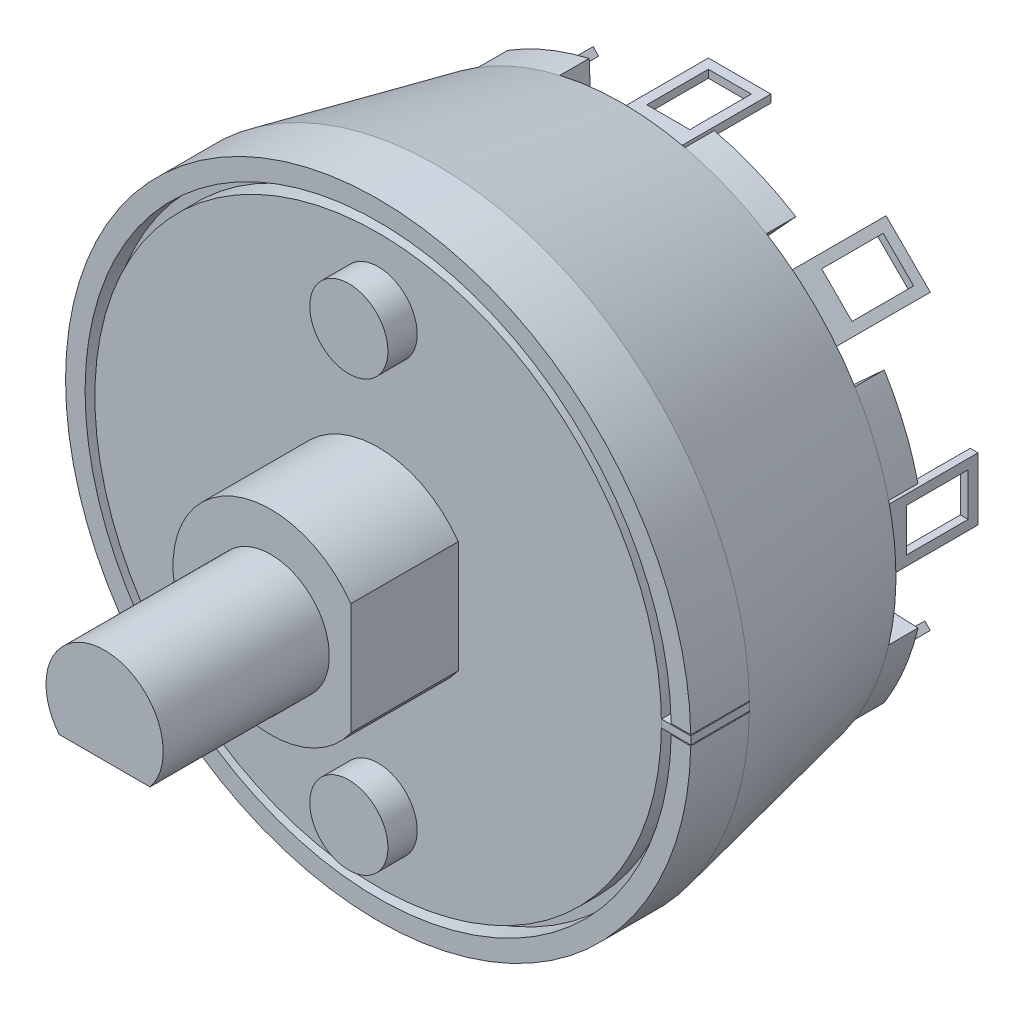
from build123d import *

# Parameters (mm, degrees)
CORTAR_EXTRUIR1_DEPTH   = 6.5
CORTAR_EXTRUIR2_DEPTH   = 5.5
CROQUIS6_R              = 2
SALIENTE_EXTRUIR1_DEPTH = 1.5
CROQUIS10_R             = 15
CROQUIS10_R_2           = 14.5
CORTAR_EXTRUIR5_DEPTH   = 1
CORTAR_EXTRUIR6_DEPTH   = 3
CROQUIS12_W             = 1.498741956
CROQUIS12_H             = 0.4
SALIENTE_EXTRUIR5_DEPTH = 3
SALIENTE_EXTRUIR6_DEPTH = 1.5
CROQUIS13_3_W           = 3.2
CROQUIS13_3_H           = 0.4
CROQUIS13_3_W_2         = 0.4
CROQUIS13_3_H_2         = 1.6
CROQUIS13_3_H_3         = 3.2
SALIENTE_EXTRUIR7_DEPTH = 6
CROQUIS14_W             = 2.2
CROQUIS14_H             = 3.15
CORTAR_EXTRUIR8_DEPTH   = 29.2
CROQUIS16_W             = 3.15
CROQUIS16_H             = 2.2
CORTAR_EXTRUIR10_DEPTH  = 35.827416998
CROQUIS17_W             = 3.15
CROQUIS17_H             = 2.2
CORTAR_EXTRUIR11_DEPTH  = 35.827416998
CROQUIS18_W             = 0.4
CROQUIS18_H             = 3.2
SALIENTE_EXTRUIR8_DEPTH = 6
CROQUIS15_W             = 3.15
CROQUIS15_H             = 2.2
CORTAR_EXTRUIR12_DEPTH  = 29.2


with BuildPart() as part:
    # Croquis3 → Revolución1 (revolve)
    with BuildSketch(Plane(origin=(0, 0, 0), x_dir=(0, 0, -1), z_dir=(1, 0, 0))):
        Polygon((0, 0), (0, 3), (8.5, 3), (8.5, 5), (14, 5), (14, 16), (17, 16), (26.5, 14), (26.5, 0), align=None)
    revolve(axis=Axis((0, 0, -26.5), (0, 0, 1)))

    # Croquis4 → Cortar-Extruir1 (cut)
    with BuildSketch(Plane.XY):
        with BuildLine():
            Line((-2.321637353, -1.9), (2.321637353, -1.9))
            ThreePointArc((2.321637353, -1.9), (0, -3), (-2.321637353, -1.9))
        make_face()
    extrude(amount=-CORTAR_EXTRUIR1_DEPTH, mode=Mode.SUBTRACT)

    # Croquis5 → Cortar-Extruir2 (cut)
    with BuildSketch(Plane.XY.offset(-8.5)):
        with BuildLine():
            Line((4.1, 2.861817604), (4.1, -2.861817604))
            ThreePointArc((4.1, -2.861817604), (5, 0), (4.1, 2.861817604))
        make_face()
    extrude(amount=-CORTAR_EXTRUIR2_DEPTH, mode=Mode.SUBTRACT)

    # Croquis6 → Saliente-Extruir1 (add)
    with BuildSketch(Plane.XY.offset(-14)):
        with Locations((0, 11)):
            Circle(CROQUIS6_R)
        with Locations((0, -11)):
            Circle(CROQUIS6_R)
    extrude(amount=SALIENTE_EXTRUIR1_DEPTH)

    # Croquis10 → Cortar-Extruir5 (cut)
    with BuildSketch(Plane.XY.offset(-14)):
        Circle(CROQUIS10_R)
        Circle(CROQUIS10_R_2, mode=Mode.SUBTRACT)
    extrude(amount=-CORTAR_EXTRUIR5_DEPTH, mode=Mode.SUBTRACT)

    # Croquis11 → Cortar-Extruir6 (cut)
    with BuildSketch(Plane.XY.offset(-14)):
        with BuildLine():
            Line((14.5, 0), (14.5, -0.25))
            Line((14.5, -0.25), (15.998046756, -0.25))
            ThreePointArc((15.998046756, -0.25), (15.999511681, -0.125003815), (16, 0))
            ThreePointArc((16, 0), (15.999511681, 0.125003815), (15.998046756, 0.25))
            Line((15.998046756, 0.25), (14.5, 0.25))
            Line((14.5, 0.25), (14.5, 0))
        make_face()
    extrude(amount=-CORTAR_EXTRUIR6_DEPTH, mode=Mode.SUBTRACT)

    # Croquis13 → Saliente-Extruir6 (add)
    with BuildSketch(Plane(origin=(0, 0, -26.5), x_dir=(-1, 0, 0), z_dir=(0, 0, -1))):
        with BuildLine():
            ThreePointArc((7.374685343, 11.900168742), (5.357568053, 12.934313455), (3.2, 13.62938003))
            Line((3.2, 13.62938003), (3.021135931, 9.532719323))
            ThreePointArc((3.021135931, 9.532719323), (3.826834324, 9.238795325), (4.604384773, 8.87691618))
            Line((4.604384773, 8.87691618), (7.374685343, 11.900168742))
        make_face()
        with BuildLine():
            ThreePointArc((13.62938003, 3.2), (12.934313455, 5.357568053), (11.900168742, 7.374685343))
            Line((11.900168742, 7.374685343), (8.87691618, 4.604384773))
            ThreePointArc((8.87691618, 4.604384773), (9.238795325, 3.826834324), (9.532719323, 3.021135931))
            Line((9.532719323, 3.021135931), (13.62938003, 3.2))
        make_face()
        with BuildLine():
            ThreePointArc((11.900168742, -7.374685343), (12.934313455, -5.357568053), (13.62938003, -3.2))
            Line((13.62938003, -3.2), (9.532719323, -3.021135931))
            ThreePointArc((9.532719323, -3.021135931), (9.238795325, -3.826834324), (8.87691618, -4.604384773))
            Line((8.87691618, -4.604384773), (11.900168742, -7.374685343))
        make_face()
        with BuildLine():
            ThreePointArc((3.2, -13.62938003), (5.357568053, -12.934313455), (7.374685343, -11.900168742))
            Line((7.374685343, -11.900168742), (4.604384773, -8.87691618))
            ThreePointArc((4.604384773, -8.87691618), (3.826834324, -9.238795325), (3.021135931, -9.532719323))
            Line((3.021135931, -9.532719323), (3.2, -13.62938003))
        make_face()
        with BuildLine():
            Line((-4.604384773, -8.87691618), (-7.374685343, -11.900168742))
            ThreePointArc((-7.374685343, -11.900168742), (-5.357568053, -12.934313455), (-3.2, -13.62938003))
            Line((-3.2, -13.62938003), (-3.021135931, -9.532719323))
            ThreePointArc((-3.021135931, -9.532719323), (-3.826834324, -9.238795325), (-4.604384773, -8.87691618))
        make_face()
        with BuildLine():
            Line((-9.532719323, -3.021135931), (-13.62938003, -3.2))
            ThreePointArc((-13.62938003, -3.2), (-12.934313455, -5.357568053), (-11.900168742, -7.374685343))
            Line((-11.900168742, -7.374685343), (-8.87691618, -4.604384773))
            ThreePointArc((-8.87691618, -4.604384773), (-9.238795325, -3.826834324), (-9.532719323, -3.021135931))
        make_face()
        with BuildLine():
            Line((-8.87691618, 4.604384773), (-11.900168742, 7.374685343))
            ThreePointArc((-11.900168742, 7.374685343), (-12.934313455, 5.357568053), (-13.62938003, 3.2))
            Line((-13.62938003, 3.2), (-9.532719323, 3.021135931))
            ThreePointArc((-9.532719323, 3.021135931), (-9.238795325, 3.826834324), (-8.87691618, 4.604384773))
        make_face()
        with BuildLine():
            Line((-3.021135931, 9.532719323), (-3.2, 13.62938003))
            ThreePointArc((-3.2, 13.62938003), (-5.357568053, 12.934313455), (-7.374685343, 11.900168742))
            Line((-7.374685343, 11.900168742), (-4.604384773, 8.87691618))
            ThreePointArc((-4.604384773, 8.87691618), (-3.826834324, 9.238795325), (-3.021135931, 9.532719323))
        make_face()
    extrude(amount=SALIENTE_EXTRUIR6_DEPTH)

    # Croquis13_3 → Saliente-Extruir7 (add)
    with BuildSketch(Plane(origin=(0, 0, -26.5), x_dir=(-1, 0, 0), z_dir=(0, 0, -1))):
        with Locations((0, 12)):
            Rectangle(CROQUIS13_3_W, CROQUIS13_3_H)
        Polygon((7.495331881, 9.75807358), (9.75807358, 7.495331881), (9.475230868, 7.212489168), (7.212489168, 9.475230868), align=None)
        Polygon((-9.75807358, 7.495331881), (-7.495331881, 9.75807358), (-7.212489168, 9.475230868), (-9.475230868, 7.212489168), align=None)
        with Locations((-12, -0.8)):
            Rectangle(CROQUIS13_3_W_2, CROQUIS13_3_H_2)
        with Locations((-12, 0.8)):
            Rectangle(CROQUIS13_3_W_2, CROQUIS13_3_H_2)
        Polygon((-7.495331881, -9.75807358), (-9.75807358, -7.495331881), (-9.475230868, -7.212489168), (-7.212489168, -9.475230868), align=None)
        with Locations((0, -12)):
            Rectangle(CROQUIS13_3_W, CROQUIS13_3_H)
        Polygon((9.75807358, -7.495331881), (7.495331881, -9.75807358), (7.212489168, -9.475230868), (9.475230868, -7.212489168), align=None)
        with Locations((12, 0)):
            Rectangle(CROQUIS13_3_W_2, CROQUIS13_3_H_3)
    extrude(amount=SALIENTE_EXTRUIR7_DEPTH)

    # Croquis14 → Cortar-Extruir8 (cut, through all)
    with BuildSketch(Plane(origin=(0, 12.2, 0), x_dir=(1, 0, 0), z_dir=(0, 1, 0))):
        with Locations((0, 30.425)):
            Rectangle(CROQUIS14_W, CROQUIS14_H)
    extrude(amount=-CORTAR_EXTRUIR8_DEPTH, mode=Mode.SUBTRACT)

    # Croquis16 → Cortar-Extruir10 (cut, through all)
    with BuildSketch(Plane(origin=(-8.62670273, 8.62670273, 0), x_dir=(0, 0, 1), z_dir=(-0.707106781, 0.707106781, 0))):
        with Locations((-30.425, 0)):
            Rectangle(CROQUIS16_W, CROQUIS16_H)
    extrude(amount=-CORTAR_EXTRUIR10_DEPTH, mode=Mode.SUBTRACT)

    # Croquis17 → Cortar-Extruir11 (cut, through all)
    with BuildSketch(Plane(origin=(-8.62670273, -8.62670273, 0), x_dir=(0, 0, 1), z_dir=(-0.707106781, -0.707106781, 0))):
        with Locations((-30.425, 0)):
            Rectangle(CROQUIS17_W, CROQUIS17_H)
    extrude(amount=-CORTAR_EXTRUIR11_DEPTH, mode=Mode.SUBTRACT)

    # Croquis18 → Saliente-Extruir8 (add)
    with BuildSketch(Plane(origin=(0, 0, -26.5), x_dir=(-1, 0, 0), z_dir=(0, 0, -1))):
        Rectangle(CROQUIS18_W, CROQUIS18_H)
    extrude(amount=SALIENTE_EXTRUIR8_DEPTH)

    # Croquis15 → Cortar-Extruir12 (cut, through all)
    with BuildSketch(Plane.ZY.offset(12.2)):
        with Locations((-30.425, 0)):
            Rectangle(CROQUIS15_W, CROQUIS15_H)
    extrude(amount=-CORTAR_EXTRUIR12_DEPTH, mode=Mode.SUBTRACT)


with BuildPart() as body_2:
    # Croquis12 → Saliente-Extruir5 (new body)
    with BuildSketch(Plane.XY.offset(-14)):
        with Locations((15.249370978, 0.00063854)):
            Rectangle(CROQUIS12_W, CROQUIS12_H)
    extrude(amount=-SALIENTE_EXTRUIR5_DEPTH)


solid = Compound([part.part, body_2.part])
